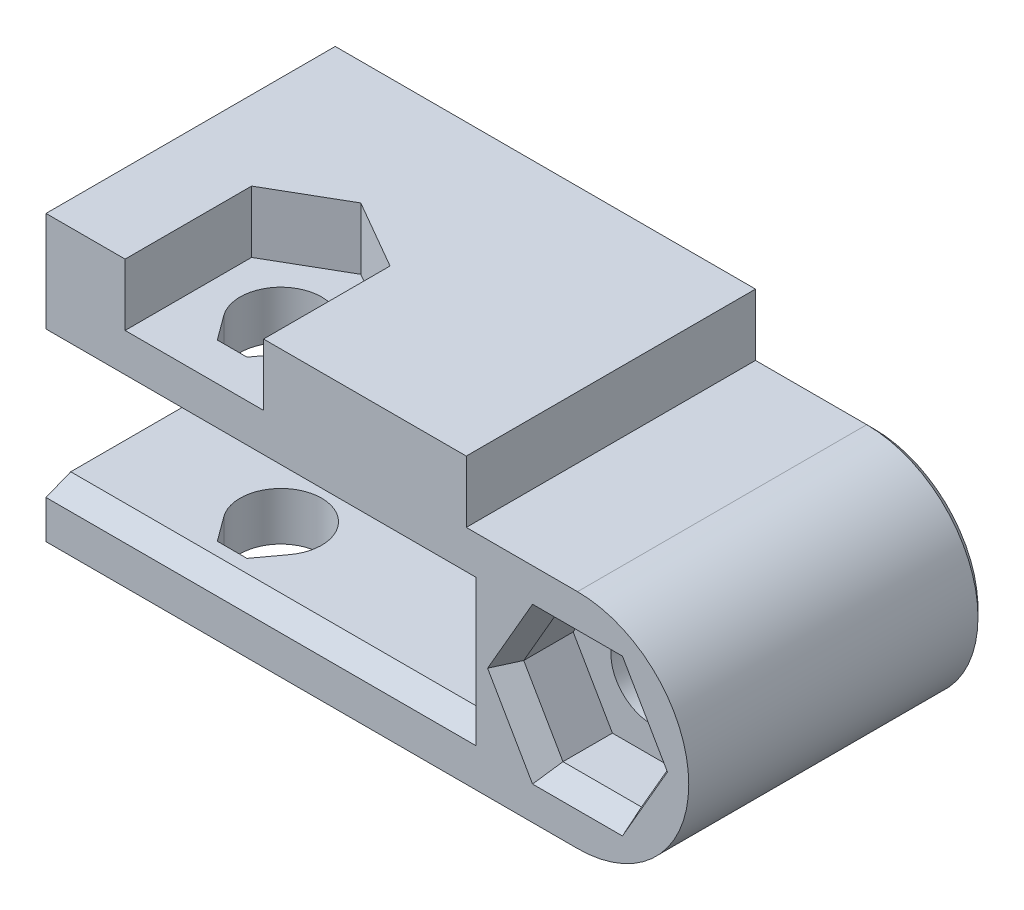
from build123d import *

# Parameters (mm, degrees)
SKETCH1_R           = 1.65
BOSS_EXTRUDE1_DEPTH = 12
SKETCH2_W           = 17
SKETCH2_H           = 5.1
CUT_EXTRUDE1_DEPTH  = 9
CUT_EXTRUDE2_DEPTH  = 3
CHAMFER1_SIZE       = 0.4
CHAMFER1_SIZE2      = 1
CHAMFER2_SIZE       = 0.3
CUT_EXTRUDE3_DEPTH  = 12.5
CUT_EXTRUDE4_DEPTH  = 2.5
SKETCH6_W           = 2
SKETCH6_H           = 5.1
CUT_EXTRUDE5_DEPTH  = 4


with BuildPart() as part:
    # Sketch1 → Boss-Extrude1 (new body)
    with BuildSketch(Plane.XY):
        with BuildLine():
            Line((-4, 7), (-4, -4.5))
            Line((-4, -4.5), (17.5, -4.5))
            ThreePointArc((17.5, -4.5), (22, 0), (17.5, 4.5))
            Line((17.5, 4.5), (13, 4.5))
            Line((13, 4.5), (13, 7))
            Line((13, 7), (-4, 7))
        make_face()
        with Locations((17.5, 0)):
            Circle(SKETCH1_R, mode=Mode.SUBTRACT)
    extrude(amount=BOSS_EXTRUDE1_DEPTH)

    # Sketch2 → Cut-Extrude1 (cut)
    with BuildSketch(Plane.XY.offset(12)):
        with Locations((4.5, 0)):
            Rectangle(SKETCH2_W, SKETCH2_H)
    extrude(amount=-CUT_EXTRUDE1_DEPTH, mode=Mode.SUBTRACT)

    # Sketch3 → Cut-Extrude2 (cut)
    with BuildSketch(Plane.XY.offset(12)):
        Polygon((14.324573519, 0), (15.91228676, -2.75), (19.08771324, -2.75), (20.675426481, 0), (19.08771324, 2.75), (15.91228676, 2.75), align=None)
    extrude(amount=-CUT_EXTRUDE2_DEPTH, mode=Mode.SUBTRACT)

    # Chamfer1
    chamfer1_edges = [part.edges().sort_by_distance(p)[0] for p in [
        (4.5, -2.55, 12),
        (13, 0, 12),
        (4.5, 2.55, 12),
        (15.11843014, 1.375, 12),
        (15.11843014, -1.375, 12),
        (17.5, -2.75, 12),
        (19.88156986, -1.375, 12),
        (19.88156986, 1.375, 12),
        (17.5, 2.75, 12),
    ]]
    chamfer1_side = [part.faces().sort_by_distance(p)[0] for p in [
        (4.5, 6.71570262, 12),
    ]]
    chamfer(chamfer1_edges, length=CHAMFER1_SIZE, length2=CHAMFER1_SIZE2, reference=chamfer1_side[0])

    # Chamfer2
    chamfer2_edges = [part.edges().sort_by_distance(p)[0] for p in [
        (15.85, 0, 0),
        (22, 0, 0),
        (6.75, -4.5, 0),
        (-4, 1.25, 0),
        (4.5, 7, 0),
        (13, 5.75, 0),
        (15.25, 4.5, 0),
    ]]
    chamfer(chamfer2_edges, length=CHAMFER2_SIZE)

    # Sketch4 → Cut-Extrude3 (cut, through all)
    with BuildSketch(Plane(origin=(0, -4.5, 0), x_dir=(1, 0, 0), z_dir=(0, 1, 0))):
        with BuildLine():
            Line((3.329547877, -9.477139931), (2.599853793, -10.47))
            Line((2.599853793, -10.47), (1.400146207, -10.47))
            Line((1.400146207, -10.47), (0.670452123, -9.477139931))
            ThreePointArc((0.670452123, -9.477139931), (2, -6.85), (3.329547877, -9.477139931))
        make_face()
    extrude(amount=CUT_EXTRUDE3_DEPTH, mode=Mode.SUBTRACT)

    # Sketch5 → Cut-Extrude4 (cut)
    with BuildSketch(Plane(origin=(0, 7, 0), x_dir=(1, 0, 0), z_dir=(0, 1, 0))):
        Polygon((-0.8, -12), (4.8, -12), (4.8, -6.883419246), (2, -5.266838493), (-0.8, -6.883419246), align=None)
    extrude(amount=-CUT_EXTRUDE4_DEPTH, mode=Mode.SUBTRACT)

    # Sketch6 → Cut-Extrude5 (cut, through all)
    with BuildSketch(Plane.XY.offset(3)):
        with Locations((-3, 0)):
            Rectangle(SKETCH6_W, SKETCH6_H)
    extrude(amount=-CUT_EXTRUDE5_DEPTH, mode=Mode.SUBTRACT)


solid = part.part
